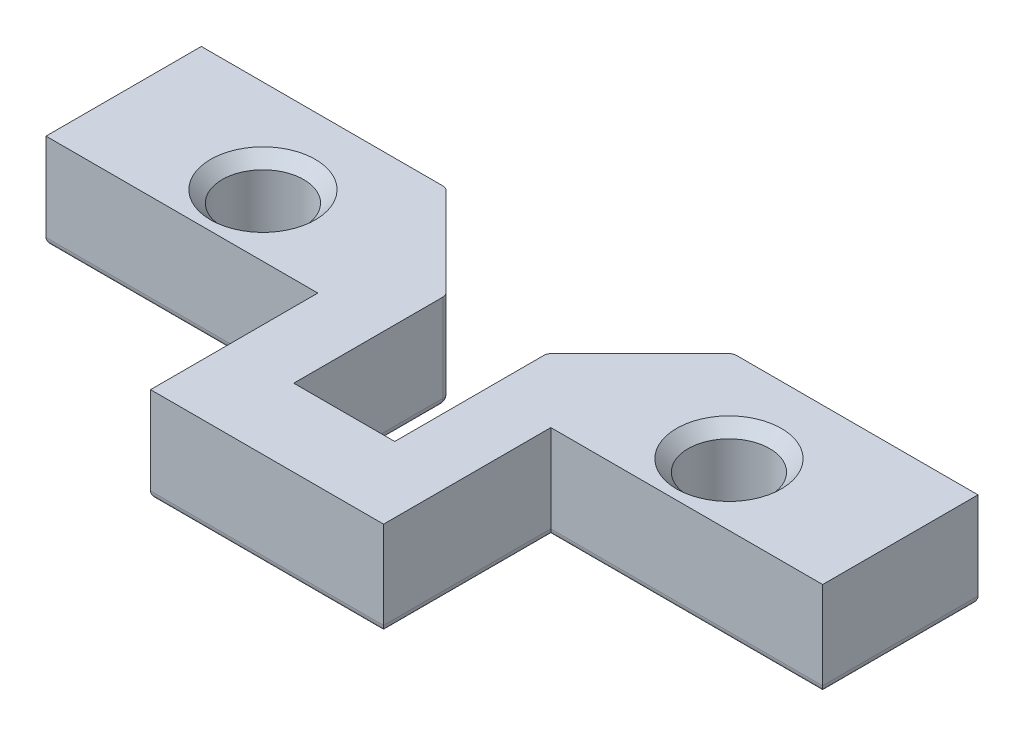
from build123d import *

# Parameters (mm, degrees)
SKETCH2_R           = 5.25
BOSS_EXTRUDE1_DEPTH = 12.3
CHAMFER1_SIZE       = 1.5
CHAMFER2_SIZE       = 12
FILLET1_R           = 1


with BuildPart() as part:
    # Sketch2 → Boss-Extrude1 (new body)
    with BuildSketch(Plane(origin=(0, 0, 0), x_dir=(1, 0, 0), z_dir=(0, 1, 0))):
        Polygon((-50, 10), (-50, -10), (-15, -10), (-6.5, -10), (-6.5, 10), align=None)
        with Locations((-30.066740906, -2)):
            Circle(SKETCH2_R, mode=Mode.SUBTRACT)
        Polygon((-6.5, -10), (-15, -10), (-15, -31.53738907), (15, -31.53738907), (15, -10), (6.5, -10), (6.5, -21.6), (-6.5, -21.6), align=None)
        Polygon((6.5, 10), (6.5, -10), (15, -10), (50, -10), (50, 10), align=None)
        with Locations((29.933259094, -2)):
            Circle(SKETCH2_R, mode=Mode.SUBTRACT)
    extrude(amount=BOSS_EXTRUDE1_DEPTH)

    # Chamfer1
    chamfer1_edges = [part.edges().sort_by_distance(p)[0] for p in [
        (-35.316740906, 12.3, 2),
        (24.683259094, 12.3, 2),
    ]]
    chamfer(chamfer1_edges, length=CHAMFER1_SIZE)

    # Chamfer2
    chamfer2_edges = [part.edges().sort_by_distance(p)[0] for p in [
        (6.5, 6.15, -10),
        (-6.5, 6.15, -10),
    ]]
    chamfer(chamfer2_edges, length=CHAMFER2_SIZE)

    # Fillet1
    fillet1_edges = [part.edges().sort_by_distance(p)[0] for p in [
        (50, 0, 0),
        (32.5, 0, 10),
        (15, 0, 20.768694535),
        (0, 0, 31.53738907),
        (-15, 0, 20.768694535),
        (-32.5, 0, 10),
        (-50, 0, 0),
        (-34.25, 0, -10),
        (-18.5, 6.15, -10),
        (-6.5, 0, 11.8),
        (6.5, 0, 11.8),
        (34.25, 0, -10),
        (12.5, 0, -4),
        (-12.5, 0, -4),
        (-6.5, 6.15, 2),
        (6.5, 6.15, 2),
        (18.5, 6.15, -10),
    ]]
    fillet(fillet1_edges, radius=FILLET1_R)


solid = part.part
